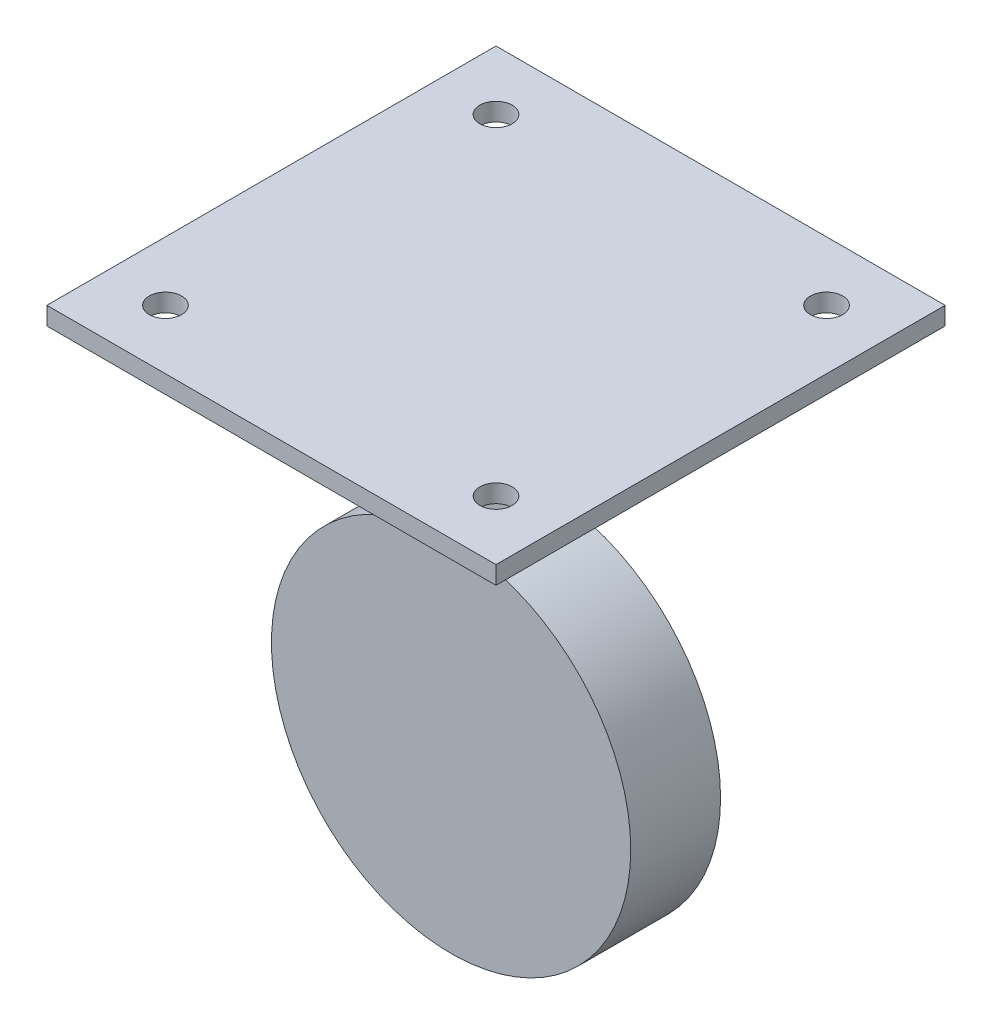
from build123d import *

# Parameters (mm, degrees)
SKETCH_1_R      = 20
EXTRUDE_1_DEPTH = 5
SKETCH_2_R      = 20
SKETCH_2_W      = 10
SKETCH_2_H      = 40
EXTRUDE_2_DEPTH = 2.5
SKETCH_3_W      = 50
SKETCH_3_H      = 50
SKETCH_3_R      = 1.8
EXTRUDE_3_DEPTH = 2


with BuildPart() as part:
    # 草图1 → 凸台-拉伸1 (new body, symmetric)
    with BuildSketch(Plane.XY):
        Circle(SKETCH_1_R)
    extrude(amount=EXTRUDE_1_DEPTH, both=True)

    # 草图2 → 凸台-拉伸2 (add, symmetric)
    with BuildSketch(Plane.XY):
        Circle(SKETCH_2_R)
        with Locations((0, 20)):
            Rectangle(SKETCH_2_W, SKETCH_2_H)
    extrude(amount=EXTRUDE_2_DEPTH, both=True)

    # 草图3 → 凸台-拉伸3 (add)
    with BuildSketch(Plane(origin=(0, 40, 0), x_dir=(1, 0, 0), z_dir=(0, 1, 0))):
        Rectangle(SKETCH_3_W, SKETCH_3_H)
        with Locations((-18.4, 18.4)):
            Circle(SKETCH_3_R, mode=Mode.SUBTRACT)
        with Locations((18.4, 18.4)):
            Circle(SKETCH_3_R, mode=Mode.SUBTRACT)
        with Locations((18.4, -18.4)):
            Circle(SKETCH_3_R, mode=Mode.SUBTRACT)
        with Locations((-18.4, -18.4)):
            Circle(SKETCH_3_R, mode=Mode.SUBTRACT)
    extrude(amount=-EXTRUDE_3_DEPTH)


solid = part.part
